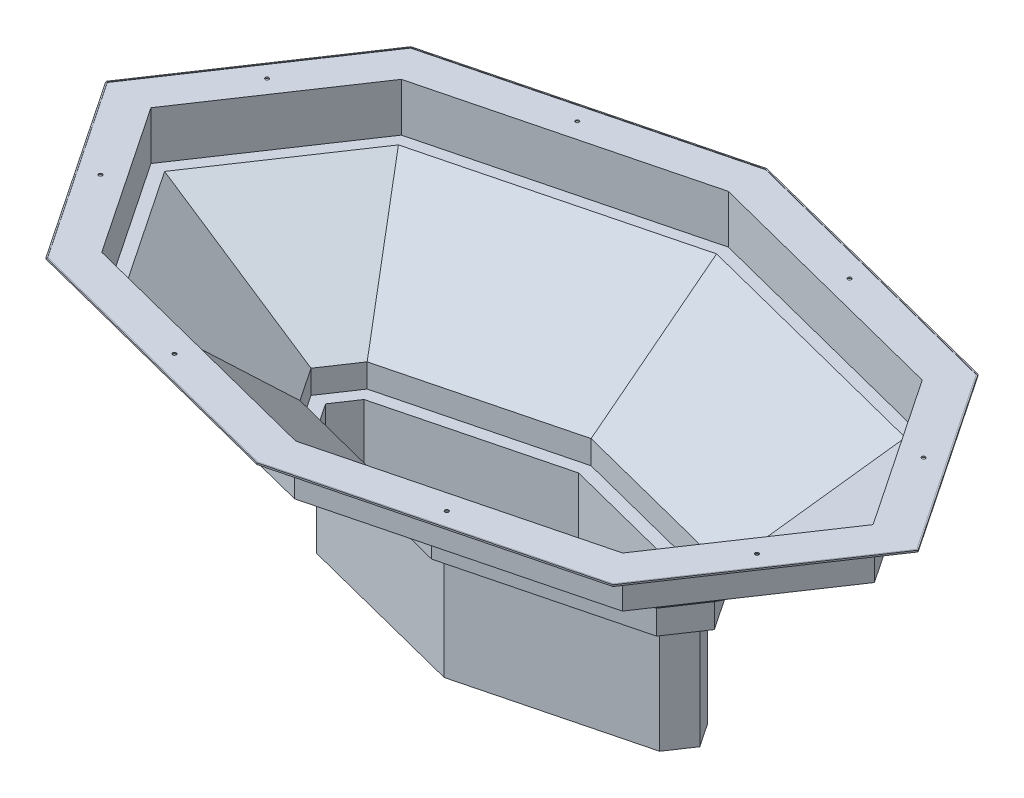
from build123d import *

# Parameters (mm, degrees)
BOSS_EXTRUDE1_DEPTH = 101.6
BOSS_EXTRUDE2_DEPTH = 50.8
BOSS_EXTRUDE3_DEPTH = 3.175
BOSS_EXTRUDE4_DEPTH = 228.6
SHELL2_T            = -2.38125
CUT_EXTRUDE1_REACH  = 589.375
SKETCH8_R           = 3.81


with BuildPart() as part:
    # Sketch1 → Boss-Extrude1 (new body)
    with BuildSketch(Plane(origin=(0, 0, 0), x_dir=(1, 0, 0), z_dir=(0, 1, 0))):
        Polygon((-762, 0), (-549.079439398, 317.011162143), (0, 457.2), (549.079439398, 317.011162143), (762, 0), (549.079439398, -317.011162143), (0, -457.2), (-549.079439398, -317.011162143), align=None)
    extrude(amount=-BOSS_EXTRUDE1_DEPTH)

    # Sketch3 → Loft1 section 0
    with BuildSketch(Plane.XZ.offset(101.6)):
        Polygon((-533.400550152, -294.79943793), (0, -430.985202453), (533.400550152, -294.79943793), (731.402605238, 0), (533.400550152, 294.79943793), (0, 430.985202453), (-533.400550152, 294.79943793), (-731.402605238, 0), align=None)
    # Sketch2 → Loft1 section 1
    with BuildSketch(Plane(origin=(0, -304.8, 0), x_dir=(-1, 0, 0), z_dir=(0, -1, 0))):
        Polygon((-425.428657613, 0), (-376.611657696, -72.682195802), (0, -168.837226983), (376.611657696, -72.682195802), (425.428657613, 0), (376.611657696, 72.682195802), (0, 168.837226983), (-376.611657696, 72.682195802), align=None)
    loft()

    # Sketch4 → Boss-Extrude2 (add)
    with BuildSketch(Plane.XZ.offset(304.8)):
        Polygon((0, -168.837226983), (376.611657696, -72.682195802), (425.428657613, 0), (376.611657696, 72.682195802), (0, 168.837226983), (-376.611657696, 72.682195802), (-425.428657613, 0), (-376.611657696, -72.682195802), align=None)
    extrude(amount=BOSS_EXTRUDE2_DEPTH)

    # Sketch5 → Boss-Extrude3 (add)
    with BuildSketch(Plane(origin=(0, 0, 0), x_dir=(1, 0, 0), z_dir=(0, 1, 0))):
        Polygon((0, 535.844392641), (-596.116107134, 383.646334781), (-853.792184287, 0), (-596.116107134, -383.646334781), (0, -535.844392641), (596.116107134, -383.646334781), (853.792184287, 0), (596.116107134, 383.646334781), align=None)
    extrude(amount=BOSS_EXTRUDE3_DEPTH)

    # Sketch6 → Boss-Extrude4 (add)
    with BuildSketch(Plane.XZ.offset(355.6)):
        Polygon((0, 142.622429435), (-360.932768451, 50.470471589), (-394.831262851, 0), (-360.932768451, -50.470471589), (0, -142.622429435), (360.932768451, -50.470471589), (394.831262851, 0), (360.932768451, 50.470471589), align=None)
    extrude(amount=BOSS_EXTRUDE4_DEPTH)

    # Shell2
    shell2_openings = [part.faces().sort_by_distance(p)[0] for p in [
        (0, 3.175, 0),
    ]]
    offset(amount=SHELL2_T, openings=shell2_openings, kind=Kind.INTERSECTION)

    # Sketch8 → Cut-Extrude1 (cut, up to next)
    with BuildSketch(Plane(origin=(0, 3.175, 0), x_dir=(1, 0, 0), z_dir=(0, 1, 0)), mode=Mode.PRIVATE) as cut_extrude1_sk1:
        with Locations((-286.298886633, 423.425472391)):
            Circle(SKETCH8_R)
    cut_extrude1_tool1 = extrude(cut_extrude1_sk1.sketch, amount=-CUT_EXTRUDE1_REACH, mode=Mode.PRIVATE) & part.part
    add(cut_extrude1_tool1.solids().sort_by_distance((-286.298887, 3.175, -423.425472))[0], mode=Mode.SUBTRACT)
    # Sketch8 → Cut-Extrude1 (cut, up to next)
    with BuildSketch(Plane(origin=(0, 3.175, 0), x_dir=(1, 0, 0), z_dir=(0, 1, 0)), mode=Mode.PRIVATE) as cut_extrude1_sk2:
        with Locations((286.298886633, 423.425472391)):
            Circle(SKETCH8_R)
    cut_extrude1_tool2 = extrude(cut_extrude1_sk2.sketch, amount=-CUT_EXTRUDE1_REACH, mode=Mode.PRIVATE) & part.part
    add(cut_extrude1_tool2.solids().sort_by_distance((286.298887, 3.175, -423.425472))[0], mode=Mode.SUBTRACT)
    # Sketch8 → Cut-Extrude1 (cut, up to next)
    with BuildSketch(Plane(origin=(0, 3.175, 0), x_dir=(1, 0, 0), z_dir=(0, 1, 0)), mode=Mode.PRIVATE) as cut_extrude1_sk3:
        with Locations((690.246932705, 175.164374231)):
            Circle(SKETCH8_R)
    cut_extrude1_tool3 = extrude(cut_extrude1_sk3.sketch, amount=-CUT_EXTRUDE1_REACH, mode=Mode.PRIVATE) & part.part
    add(cut_extrude1_tool3.solids().sort_by_distance((690.246933, 3.175, -175.164374))[0], mode=Mode.SUBTRACT)
    # Sketch8 → Cut-Extrude1 (cut, up to next)
    with BuildSketch(Plane(origin=(0, 3.175, 0), x_dir=(1, 0, 0), z_dir=(0, 1, 0)), mode=Mode.PRIVATE) as cut_extrude1_sk4:
        with Locations((690.246932705, -175.164374231)):
            Circle(SKETCH8_R)
    cut_extrude1_tool4 = extrude(cut_extrude1_sk4.sketch, amount=-CUT_EXTRUDE1_REACH, mode=Mode.PRIVATE) & part.part
    add(cut_extrude1_tool4.solids().sort_by_distance((690.246933, 3.175, 175.164374))[0], mode=Mode.SUBTRACT)
    # Sketch8 → Cut-Extrude1 (cut, up to next)
    with BuildSketch(Plane(origin=(0, 3.175, 0), x_dir=(1, 0, 0), z_dir=(0, 1, 0)), mode=Mode.PRIVATE) as cut_extrude1_sk5:
        with Locations((286.298886633, -423.425472391)):
            Circle(SKETCH8_R)
    cut_extrude1_tool5 = extrude(cut_extrude1_sk5.sketch, amount=-CUT_EXTRUDE1_REACH, mode=Mode.PRIVATE) & part.part
    add(cut_extrude1_tool5.solids().sort_by_distance((286.298887, 3.175, 423.425472))[0], mode=Mode.SUBTRACT)
    # Sketch8 → Cut-Extrude1 (cut, up to next)
    with BuildSketch(Plane(origin=(0, 3.175, 0), x_dir=(1, 0, 0), z_dir=(0, 1, 0)), mode=Mode.PRIVATE) as cut_extrude1_sk6:
        with Locations((-286.298886633, -423.425472391)):
            Circle(SKETCH8_R)
    cut_extrude1_tool6 = extrude(cut_extrude1_sk6.sketch, amount=-CUT_EXTRUDE1_REACH, mode=Mode.PRIVATE) & part.part
    add(cut_extrude1_tool6.solids().sort_by_distance((-286.298887, 3.175, 423.425472))[0], mode=Mode.SUBTRACT)
    # Sketch8 → Cut-Extrude1 (cut, up to next)
    with BuildSketch(Plane(origin=(0, 3.175, 0), x_dir=(1, 0, 0), z_dir=(0, 1, 0)), mode=Mode.PRIVATE) as cut_extrude1_sk7:
        with Locations((-690.246932705, -175.164374231)):
            Circle(SKETCH8_R)
    cut_extrude1_tool7 = extrude(cut_extrude1_sk7.sketch, amount=-CUT_EXTRUDE1_REACH, mode=Mode.PRIVATE) & part.part
    add(cut_extrude1_tool7.solids().sort_by_distance((-690.246933, 3.175, 175.164374))[0], mode=Mode.SUBTRACT)
    # Sketch8 → Cut-Extrude1 (cut, up to next)
    with BuildSketch(Plane(origin=(0, 3.175, 0), x_dir=(1, 0, 0), z_dir=(0, 1, 0)), mode=Mode.PRIVATE) as cut_extrude1_sk8:
        with Locations((-690.246932705, 175.164374231)):
            Circle(SKETCH8_R)
    cut_extrude1_tool8 = extrude(cut_extrude1_sk8.sketch, amount=-CUT_EXTRUDE1_REACH, mode=Mode.PRIVATE) & part.part
    add(cut_extrude1_tool8.solids().sort_by_distance((-690.246933, 3.175, -175.164374))[0], mode=Mode.SUBTRACT)


solid = part.part
